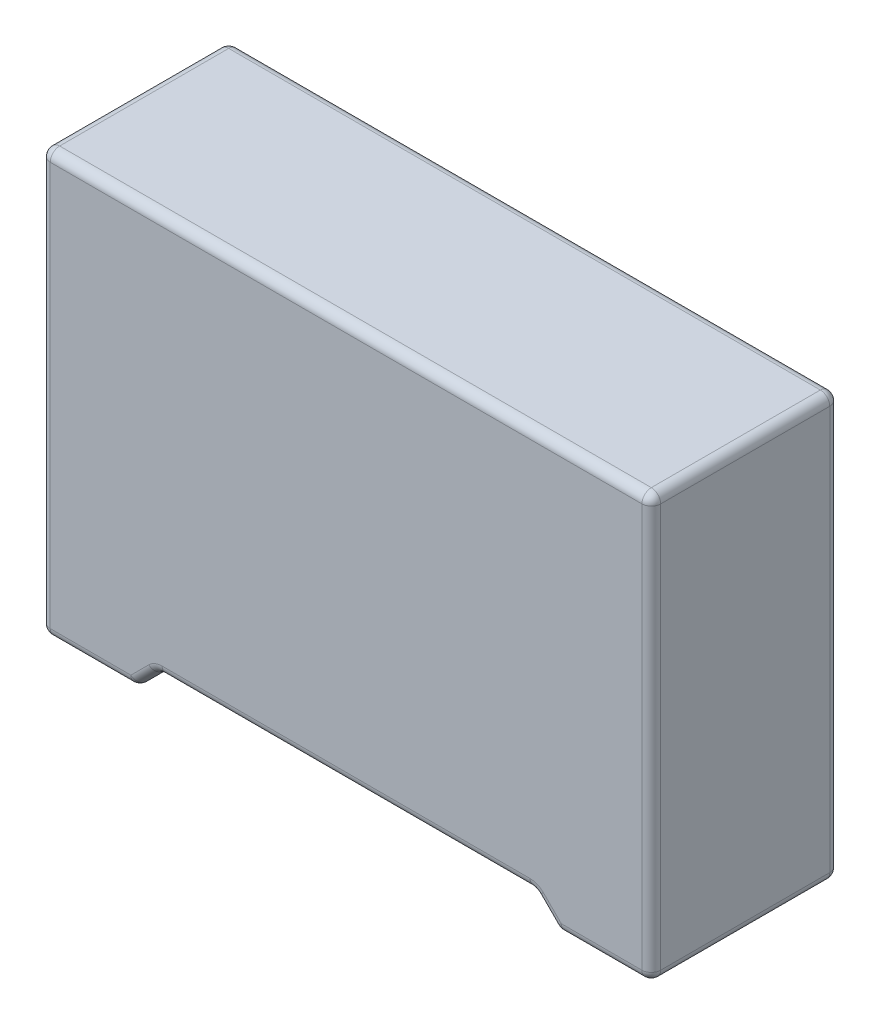
from build123d import *

# Parameters (mm, degrees)
SKETCH1_W           = 13
SKETCH1_H           = 4
BOSS_EXTRUDE1_DEPTH = 9
CUT_EXTRUDE1_DEPTH  = 5
SKETCH3_R           = 0.3
BOSS_EXTRUDE2_DEPTH = 1
FILLET1_R           = 0.2


with BuildPart() as part:
    # Sketch1 → Boss-Extrude1 (new body)
    with BuildSketch(Plane(origin=(0, 0, 0), x_dir=(1, 0, 0), z_dir=(0, 1, 0))):
        Rectangle(SKETCH1_W, SKETCH1_H)
    extrude(amount=BOSS_EXTRUDE1_DEPTH)

    # Sketch2 → Cut-Extrude1 (cut, through all)
    with BuildSketch(Plane.XY.offset(2)):
        Polygon((-4.5, 0), (-4, 0.5), (4, 0.5), (4.5, 0), (4.5, -1.5), (-4.5, -1.5), align=None)
    extrude(amount=-CUT_EXTRUDE1_DEPTH, mode=Mode.SUBTRACT)

    # Sketch3 → Boss-Extrude2 (add)
    with BuildSketch(Plane.XZ):
        with Locations((5, 0)):
            Circle(SKETCH3_R)
        with Locations((-5, 0)):
            Circle(SKETCH3_R)
    extrude(amount=BOSS_EXTRUDE2_DEPTH)

    # Fillet1
    fillet1_edges = [part.edges().sort_by_distance(p)[0] for p in [
        (6.5, 9, 0),
        (0, 9, -2),
        (-5.5, 0, -2),
        (5.5, 0, 2),
        (4.25, 0.25, 2),
        (0, 0.5, 2),
        (-4.25, 0.25, 2),
        (-4.25, 0.25, -2),
        (-4.5, 0, 0),
        (0, 0.5, -2),
        (-4, 0.5, 0),
        (4.25, 0.25, -2),
        (4, 0.5, 0),
        (4.5, 0, 0),
        (-6.5, 9, 0),
        (5.5, 0, -2),
        (6.5, 0, 0),
        (-5.5, 0, 2),
        (-6.5, 0, 0),
        (0, 9, 2),
        (-6.5, 4.5, -2),
        (6.5, 4.5, -2),
        (6.5, 4.5, 2),
        (-6.5, 4.5, 2),
    ]]
    fillet(fillet1_edges, radius=FILLET1_R)


solid = part.part
